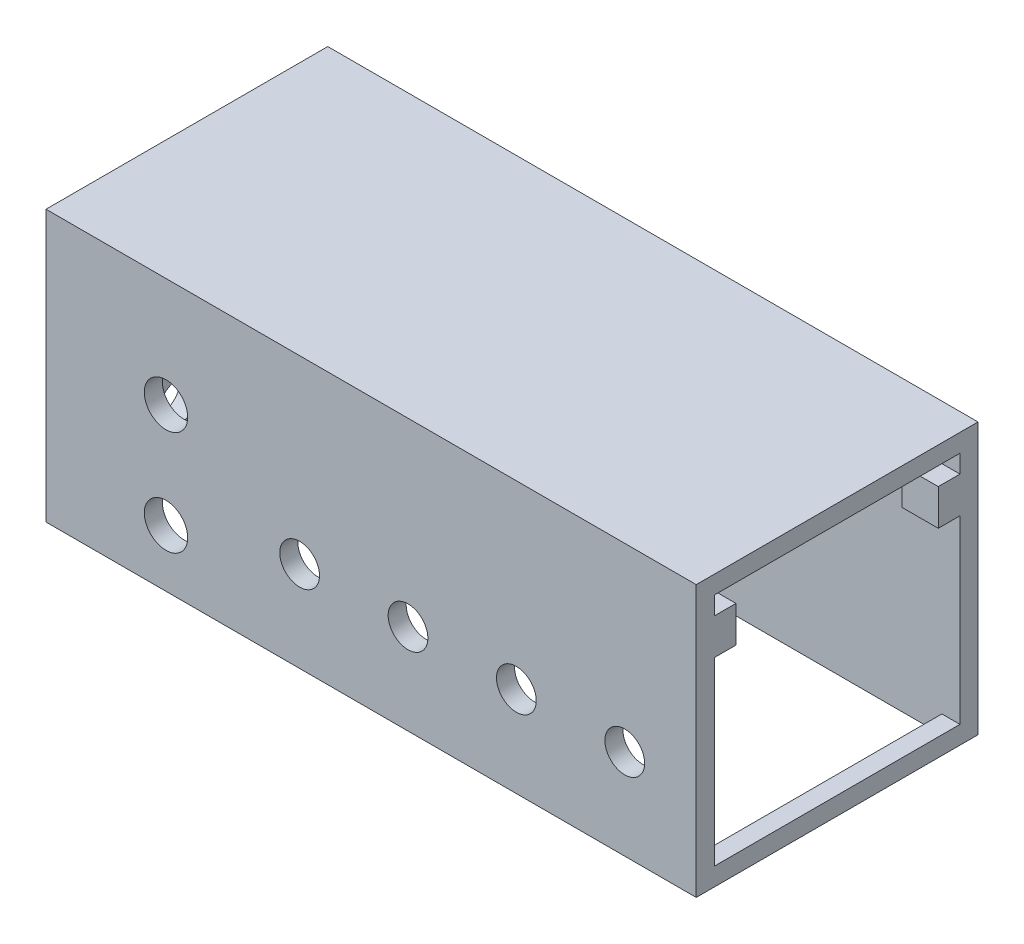
from build123d import *

# Parameters (mm, degrees)
SKETCH1_W           = 180
SKETCH1_H           = 78
BOSS_EXTRUDE1_DEPTH = 75
SKETCH7_W           = 170
SKETCH7_H           = 68
CUT_EXTRUDE1_DEPTH  = 70
SKETCH8_W           = 68
SKETCH8_H           = 65
CUT_EXTRUDE2_DEPTH  = 5
SKETCH2_R           = 5.5
SKETCH2_R_2         = 6
CUT_EXTRUDE3_DEPTH  = 5
SKETCH6_R           = 5.5
CUT_EXTRUDE5_DEPTH  = 5
SKETCH9_W           = 10
SKETCH9_H           = 10
BOSS_EXTRUDE2_DEPTH = 6


with BuildPart() as part:
    # Sketch1 → Boss-Extrude1 (new body)
    with BuildSketch(Plane(origin=(0, 0, 0), x_dir=(1, 0, 0), z_dir=(0, 1, 0))):
        with Locations((90, -39)):
            Rectangle(SKETCH1_W, SKETCH1_H)
    extrude(amount=BOSS_EXTRUDE1_DEPTH)

    # Sketch7 → Cut-Extrude1 (cut)
    with BuildSketch(Plane(origin=(0, 0, 0), x_dir=(1, 0, 0), z_dir=(0, 1, 0))):
        with Locations((90, -39)):
            Rectangle(SKETCH7_W, SKETCH7_H)
    extrude(amount=CUT_EXTRUDE1_DEPTH, mode=Mode.SUBTRACT)

    # Sketch8 → Cut-Extrude2 (cut)
    with BuildSketch(Plane(origin=(180, 0, 0), x_dir=(0, 0, -1), z_dir=(1, 0, 0))):
        with Locations((-39, 37.5)):
            Rectangle(SKETCH8_W, SKETCH8_H)
    extrude(amount=-CUT_EXTRUDE2_DEPTH, mode=Mode.SUBTRACT)

    # Sketch2 → Cut-Extrude3 (cut)
    with BuildSketch(Plane.XY.offset(78)):
        with Locations((160.21219032, 25)):
            Circle(SKETCH2_R)
        with Locations((100.21219032, 25)):
            Circle(SKETCH2_R)
        with Locations((130.21219032, 25)):
            Circle(SKETCH2_R)
        with Locations((70.21219032, 25)):
            Circle(SKETCH2_R)
        with Locations((33.219063995, 44.738868471)):
            Circle(SKETCH2_R_2)
        with Locations((33.219063995, 15.81956505)):
            Circle(SKETCH2_R_2)
    extrude(amount=-CUT_EXTRUDE3_DEPTH, mode=Mode.SUBTRACT)

    # Sketch6 → Cut-Extrude5 (cut)
    with BuildSketch(Plane(origin=(0, 0, 0), x_dir=(0, 0, -1), z_dir=(1, 0, 0))):
        with Locations((-46.363872843, 44.63646506)):
            Circle(SKETCH6_R)
        with Locations((-46.363872843, 15.486690828)):
            Circle(SKETCH6_R)
    extrude(amount=CUT_EXTRUDE5_DEPTH, mode=Mode.SUBTRACT)

    # Sketch9 → Boss-Extrude2 (add)
    with BuildSketch(Plane(origin=(0, 0, 73), x_dir=(-1, 0, 0), z_dir=(0, 0, -1))):
        with Locations((-175, 60)):
            Rectangle(SKETCH9_W, SKETCH9_H)
        with Locations((-90, 60)):
            Rectangle(SKETCH9_W, SKETCH9_H)
        with Locations((-10, 60)):
            Rectangle(SKETCH9_W, SKETCH9_H)
    boss_extrude2 = extrude(amount=BOSS_EXTRUDE2_DEPTH)

    # Mirror1: Boss-Extrude2 across plane
    add(boss_extrude2.mirror(Plane.XY.offset(39)))


solid = part.part
